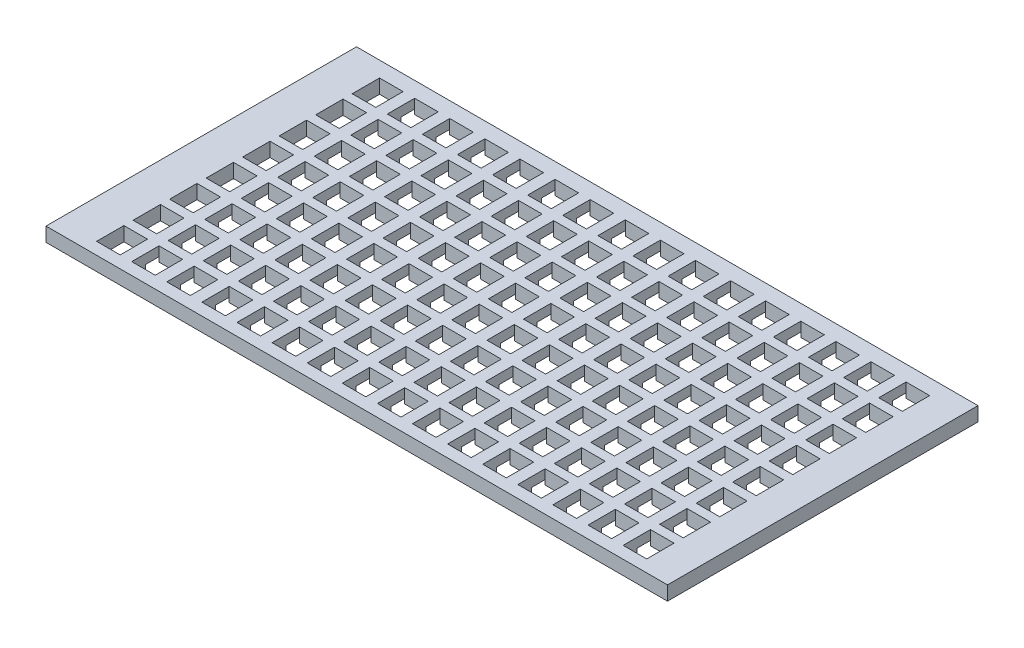
from build123d import *

# Parameters (mm, degrees)
SKETCH_1_W                  = 131.9
SKETCH_1_H                  = 65.9
EXTRUDE_1_DEPTH             = 3
SKETCH_2_W                  = 5
SKETCH_2_H                  = 5.8
CUT_EXTRUDE_2_DEPTH         = 74.784178521
SKETCH_3_W                  = 2.45
SKETCH_3_H                  = 4
CUT_EXTRUDE_3_DEPTH         = 1
PATTERN_LINEAR_1_COUNT      = 16
PATTERN_LINEAR_1_PITCH      = 7.45
PATTERN_LINEAR_1_COUNT_DIR2 = 8
PATTERN_LINEAR_1_PITCH_DIR2 = 7.75


with BuildPart() as part:
    # 草图1 → 凸台-拉伸1 (new body)
    with BuildSketch(Plane(origin=(0, 0, 0), x_dir=(1, 0, 0), z_dir=(0, 1, 0))):
        Rectangle(SKETCH_1_W, SKETCH_1_H)
    extrude(amount=EXTRUDE_1_DEPTH)

    # 草图2 → 切除-拉伸2 (cut, through all)
    with BuildSketch(Plane.XZ):
        with Locations((-55.274418084, 19.737976196)):
            Rectangle(SKETCH_2_W, SKETCH_2_H)
        with Locations((-55.274418084, 27.487976196)):
            Rectangle(SKETCH_2_W, SKETCH_2_H)
        with Locations((-55.274418084, 11.987976196)):
            Rectangle(SKETCH_2_W, SKETCH_2_H)
        with Locations((-55.274418084, 4.237976196)):
            Rectangle(SKETCH_2_W, SKETCH_2_H)
        with Locations((-55.274418084, -3.512023804)):
            Rectangle(SKETCH_2_W, SKETCH_2_H)
        with Locations((-55.274418084, -11.262023804)):
            Rectangle(SKETCH_2_W, SKETCH_2_H)
        with Locations((-55.274418084, -19.012023804)):
            Rectangle(SKETCH_2_W, SKETCH_2_H)
        with Locations((-55.274418084, -26.762023804)):
            Rectangle(SKETCH_2_W, SKETCH_2_H)
        with Locations((-47.824418084, 27.487976196)):
            Rectangle(SKETCH_2_W, SKETCH_2_H)
        with Locations((-47.824418084, 19.737976196)):
            Rectangle(SKETCH_2_W, SKETCH_2_H)
        with Locations((-47.824418084, 11.987976196)):
            Rectangle(SKETCH_2_W, SKETCH_2_H)
        with Locations((-47.824418084, 4.237976196)):
            Rectangle(SKETCH_2_W, SKETCH_2_H)
        with Locations((-47.824418084, -3.512023804)):
            Rectangle(SKETCH_2_W, SKETCH_2_H)
        with Locations((-47.824418084, -11.262023804)):
            Rectangle(SKETCH_2_W, SKETCH_2_H)
        with Locations((-47.824418084, -19.012023804)):
            Rectangle(SKETCH_2_W, SKETCH_2_H)
        with Locations((-47.824418084, -26.762023804)):
            Rectangle(SKETCH_2_W, SKETCH_2_H)
        with Locations((-40.374418084, 27.487976196)):
            Rectangle(SKETCH_2_W, SKETCH_2_H)
        with Locations((-40.374418084, 19.737976196)):
            Rectangle(SKETCH_2_W, SKETCH_2_H)
        with Locations((-40.374418084, 11.987976196)):
            Rectangle(SKETCH_2_W, SKETCH_2_H)
        with Locations((-40.374418084, 4.237976196)):
            Rectangle(SKETCH_2_W, SKETCH_2_H)
        with Locations((-40.374418084, -3.512023804)):
            Rectangle(SKETCH_2_W, SKETCH_2_H)
        with Locations((-40.374418084, -11.262023804)):
            Rectangle(SKETCH_2_W, SKETCH_2_H)
        with Locations((-40.374418084, -19.012023804)):
            Rectangle(SKETCH_2_W, SKETCH_2_H)
        with Locations((-40.374418084, -26.762023804)):
            Rectangle(SKETCH_2_W, SKETCH_2_H)
        with Locations((-32.924418084, 27.487976196)):
            Rectangle(SKETCH_2_W, SKETCH_2_H)
        with Locations((-32.924418084, 19.737976196)):
            Rectangle(SKETCH_2_W, SKETCH_2_H)
        with Locations((-32.924418084, 11.987976196)):
            Rectangle(SKETCH_2_W, SKETCH_2_H)
        with Locations((-32.924418084, 4.237976196)):
            Rectangle(SKETCH_2_W, SKETCH_2_H)
        with Locations((-32.924418084, -3.512023804)):
            Rectangle(SKETCH_2_W, SKETCH_2_H)
        with Locations((-32.924418084, -11.262023804)):
            Rectangle(SKETCH_2_W, SKETCH_2_H)
        with Locations((-32.924418084, -19.012023804)):
            Rectangle(SKETCH_2_W, SKETCH_2_H)
        with Locations((-32.924418084, -26.762023804)):
            Rectangle(SKETCH_2_W, SKETCH_2_H)
        with Locations((-25.474418084, 27.487976196)):
            Rectangle(SKETCH_2_W, SKETCH_2_H)
        with Locations((-25.474418084, 19.737976196)):
            Rectangle(SKETCH_2_W, SKETCH_2_H)
        with Locations((-25.474418084, 11.987976196)):
            Rectangle(SKETCH_2_W, SKETCH_2_H)
        with Locations((-25.474418084, 4.237976196)):
            Rectangle(SKETCH_2_W, SKETCH_2_H)
        with Locations((-25.474418084, -3.512023804)):
            Rectangle(SKETCH_2_W, SKETCH_2_H)
        with Locations((-25.474418084, -11.262023804)):
            Rectangle(SKETCH_2_W, SKETCH_2_H)
        with Locations((-25.474418084, -19.012023804)):
            Rectangle(SKETCH_2_W, SKETCH_2_H)
        with Locations((-25.474418084, -26.762023804)):
            Rectangle(SKETCH_2_W, SKETCH_2_H)
        with Locations((-18.024418084, 27.487976196)):
            Rectangle(SKETCH_2_W, SKETCH_2_H)
        with Locations((-18.024418084, 19.737976196)):
            Rectangle(SKETCH_2_W, SKETCH_2_H)
        with Locations((-18.024418084, 11.987976196)):
            Rectangle(SKETCH_2_W, SKETCH_2_H)
        with Locations((-18.024418084, 4.237976196)):
            Rectangle(SKETCH_2_W, SKETCH_2_H)
        with Locations((-18.024418084, -3.512023804)):
            Rectangle(SKETCH_2_W, SKETCH_2_H)
        with Locations((-18.024418084, -11.262023804)):
            Rectangle(SKETCH_2_W, SKETCH_2_H)
        with Locations((-18.024418084, -19.012023804)):
            Rectangle(SKETCH_2_W, SKETCH_2_H)
        with Locations((-18.024418084, -26.762023804)):
            Rectangle(SKETCH_2_W, SKETCH_2_H)
        with Locations((-10.574418084, 27.487976196)):
            Rectangle(SKETCH_2_W, SKETCH_2_H)
        with Locations((-10.574418084, 19.737976196)):
            Rectangle(SKETCH_2_W, SKETCH_2_H)
        with Locations((-10.574418084, 11.987976196)):
            Rectangle(SKETCH_2_W, SKETCH_2_H)
        with Locations((-10.574418084, 4.237976196)):
            Rectangle(SKETCH_2_W, SKETCH_2_H)
        with Locations((-10.574418084, -3.512023804)):
            Rectangle(SKETCH_2_W, SKETCH_2_H)
        with Locations((-10.574418084, -11.262023804)):
            Rectangle(SKETCH_2_W, SKETCH_2_H)
        with Locations((-10.574418084, -19.012023804)):
            Rectangle(SKETCH_2_W, SKETCH_2_H)
        with Locations((-10.574418084, -26.762023804)):
            Rectangle(SKETCH_2_W, SKETCH_2_H)
        with Locations((-3.124418084, 27.487976196)):
            Rectangle(SKETCH_2_W, SKETCH_2_H)
        with Locations((-3.124418084, 19.737976196)):
            Rectangle(SKETCH_2_W, SKETCH_2_H)
        with Locations((-3.124418084, 11.987976196)):
            Rectangle(SKETCH_2_W, SKETCH_2_H)
        with Locations((-3.124418084, 4.237976196)):
            Rectangle(SKETCH_2_W, SKETCH_2_H)
        with Locations((-3.124418084, -3.512023804)):
            Rectangle(SKETCH_2_W, SKETCH_2_H)
        with Locations((-3.124418084, -11.262023804)):
            Rectangle(SKETCH_2_W, SKETCH_2_H)
        with Locations((-3.124418084, -19.012023804)):
            Rectangle(SKETCH_2_W, SKETCH_2_H)
        with Locations((-3.124418084, -26.762023804)):
            Rectangle(SKETCH_2_W, SKETCH_2_H)
        with Locations((4.325581916, 27.487976196)):
            Rectangle(SKETCH_2_W, SKETCH_2_H)
        with Locations((4.325581916, 19.737976196)):
            Rectangle(SKETCH_2_W, SKETCH_2_H)
        with Locations((4.325581916, 11.987976196)):
            Rectangle(SKETCH_2_W, SKETCH_2_H)
        with Locations((4.325581916, 4.237976196)):
            Rectangle(SKETCH_2_W, SKETCH_2_H)
        with Locations((4.325581916, -3.512023804)):
            Rectangle(SKETCH_2_W, SKETCH_2_H)
        with Locations((4.325581916, -11.262023804)):
            Rectangle(SKETCH_2_W, SKETCH_2_H)
        with Locations((4.325581916, -19.012023804)):
            Rectangle(SKETCH_2_W, SKETCH_2_H)
        with Locations((4.325581916, -26.762023804)):
            Rectangle(SKETCH_2_W, SKETCH_2_H)
        with Locations((11.775581916, 27.487976196)):
            Rectangle(SKETCH_2_W, SKETCH_2_H)
        with Locations((11.775581916, 19.737976196)):
            Rectangle(SKETCH_2_W, SKETCH_2_H)
        with Locations((11.775581916, 11.987976196)):
            Rectangle(SKETCH_2_W, SKETCH_2_H)
        with Locations((11.775581916, 4.237976196)):
            Rectangle(SKETCH_2_W, SKETCH_2_H)
        with Locations((11.775581916, -3.512023804)):
            Rectangle(SKETCH_2_W, SKETCH_2_H)
        with Locations((11.775581916, -11.262023804)):
            Rectangle(SKETCH_2_W, SKETCH_2_H)
        with Locations((11.775581916, -19.012023804)):
            Rectangle(SKETCH_2_W, SKETCH_2_H)
        with Locations((11.775581916, -26.762023804)):
            Rectangle(SKETCH_2_W, SKETCH_2_H)
        with Locations((19.225581916, 27.487976196)):
            Rectangle(SKETCH_2_W, SKETCH_2_H)
        with Locations((19.225581916, 19.737976196)):
            Rectangle(SKETCH_2_W, SKETCH_2_H)
        with Locations((19.225581916, 11.987976196)):
            Rectangle(SKETCH_2_W, SKETCH_2_H)
        with Locations((19.225581916, 4.237976196)):
            Rectangle(SKETCH_2_W, SKETCH_2_H)
        with Locations((19.225581916, -3.512023804)):
            Rectangle(SKETCH_2_W, SKETCH_2_H)
        with Locations((19.225581916, -11.262023804)):
            Rectangle(SKETCH_2_W, SKETCH_2_H)
        with Locations((19.225581916, -19.012023804)):
            Rectangle(SKETCH_2_W, SKETCH_2_H)
        with Locations((19.225581916, -26.762023804)):
            Rectangle(SKETCH_2_W, SKETCH_2_H)
        with Locations((26.675581916, 27.487976196)):
            Rectangle(SKETCH_2_W, SKETCH_2_H)
        with Locations((26.675581916, 19.737976196)):
            Rectangle(SKETCH_2_W, SKETCH_2_H)
        with Locations((26.675581916, 11.987976196)):
            Rectangle(SKETCH_2_W, SKETCH_2_H)
        with Locations((26.675581916, 4.237976196)):
            Rectangle(SKETCH_2_W, SKETCH_2_H)
        with Locations((26.675581916, -3.512023804)):
            Rectangle(SKETCH_2_W, SKETCH_2_H)
        with Locations((26.675581916, -11.262023804)):
            Rectangle(SKETCH_2_W, SKETCH_2_H)
        with Locations((26.675581916, -19.012023804)):
            Rectangle(SKETCH_2_W, SKETCH_2_H)
        with Locations((26.675581916, -26.762023804)):
            Rectangle(SKETCH_2_W, SKETCH_2_H)
        with Locations((34.125581916, 27.487976196)):
            Rectangle(SKETCH_2_W, SKETCH_2_H)
        with Locations((34.125581916, 19.737976196)):
            Rectangle(SKETCH_2_W, SKETCH_2_H)
        with Locations((34.125581916, 11.987976196)):
            Rectangle(SKETCH_2_W, SKETCH_2_H)
        with Locations((34.125581916, 4.237976196)):
            Rectangle(SKETCH_2_W, SKETCH_2_H)
        with Locations((34.125581916, -3.512023804)):
            Rectangle(SKETCH_2_W, SKETCH_2_H)
        with Locations((34.125581916, -11.262023804)):
            Rectangle(SKETCH_2_W, SKETCH_2_H)
        with Locations((34.125581916, -19.012023804)):
            Rectangle(SKETCH_2_W, SKETCH_2_H)
        with Locations((34.125581916, -26.762023804)):
            Rectangle(SKETCH_2_W, SKETCH_2_H)
        with Locations((41.575581916, 27.487976196)):
            Rectangle(SKETCH_2_W, SKETCH_2_H)
        with Locations((41.575581916, 19.737976196)):
            Rectangle(SKETCH_2_W, SKETCH_2_H)
        with Locations((41.575581916, 11.987976196)):
            Rectangle(SKETCH_2_W, SKETCH_2_H)
        with Locations((41.575581916, 4.237976196)):
            Rectangle(SKETCH_2_W, SKETCH_2_H)
        with Locations((41.575581916, -3.512023804)):
            Rectangle(SKETCH_2_W, SKETCH_2_H)
        with Locations((41.575581916, -11.262023804)):
            Rectangle(SKETCH_2_W, SKETCH_2_H)
        with Locations((41.575581916, -19.012023804)):
            Rectangle(SKETCH_2_W, SKETCH_2_H)
        with Locations((41.575581916, -26.762023804)):
            Rectangle(SKETCH_2_W, SKETCH_2_H)
        with Locations((49.025581916, 27.487976196)):
            Rectangle(SKETCH_2_W, SKETCH_2_H)
        with Locations((49.025581916, 19.737976196)):
            Rectangle(SKETCH_2_W, SKETCH_2_H)
        with Locations((49.025581916, 11.987976196)):
            Rectangle(SKETCH_2_W, SKETCH_2_H)
        with Locations((49.025581916, 4.237976196)):
            Rectangle(SKETCH_2_W, SKETCH_2_H)
        with Locations((49.025581916, -3.512023804)):
            Rectangle(SKETCH_2_W, SKETCH_2_H)
        with Locations((49.025581916, -11.262023804)):
            Rectangle(SKETCH_2_W, SKETCH_2_H)
        with Locations((49.025581916, -19.012023804)):
            Rectangle(SKETCH_2_W, SKETCH_2_H)
        with Locations((49.025581916, -26.762023804)):
            Rectangle(SKETCH_2_W, SKETCH_2_H)
        with Locations((56.475581916, 27.487976196)):
            Rectangle(SKETCH_2_W, SKETCH_2_H)
        with Locations((56.475581916, 19.737976196)):
            Rectangle(SKETCH_2_W, SKETCH_2_H)
        with Locations((56.475581916, 11.987976196)):
            Rectangle(SKETCH_2_W, SKETCH_2_H)
        with Locations((56.475581916, 4.237976196)):
            Rectangle(SKETCH_2_W, SKETCH_2_H)
        with Locations((56.475581916, -3.512023804)):
            Rectangle(SKETCH_2_W, SKETCH_2_H)
        with Locations((56.475581916, -11.262023804)):
            Rectangle(SKETCH_2_W, SKETCH_2_H)
        with Locations((56.475581916, -19.012023804)):
            Rectangle(SKETCH_2_W, SKETCH_2_H)
        with Locations((56.475581916, -26.762023804)):
            Rectangle(SKETCH_2_W, SKETCH_2_H)
    extrude(amount=-CUT_EXTRUDE_2_DEPTH, mode=Mode.SUBTRACT)

    # 草图3 → 切除-拉伸3 (cut)
    with BuildSketch(Plane.XZ):
        with Locations((60.200581916, 25.487976196)):
            Rectangle(SKETCH_3_W, SKETCH_3_H)
    cut_extrude_3 = extrude(amount=-CUT_EXTRUDE_3_DEPTH, mode=Mode.SUBTRACT)

    # 阵列(线性)1: Cut-Extrude 3 16 × 8
    with Locations(*[(-i * PATTERN_LINEAR_1_PITCH, 0, -j * PATTERN_LINEAR_1_PITCH_DIR2) for i in range(PATTERN_LINEAR_1_COUNT) for j in range(PATTERN_LINEAR_1_COUNT_DIR2) if (i, j) != (0, 0)]):
        add(cut_extrude_3, mode=Mode.SUBTRACT)


solid = part.part
